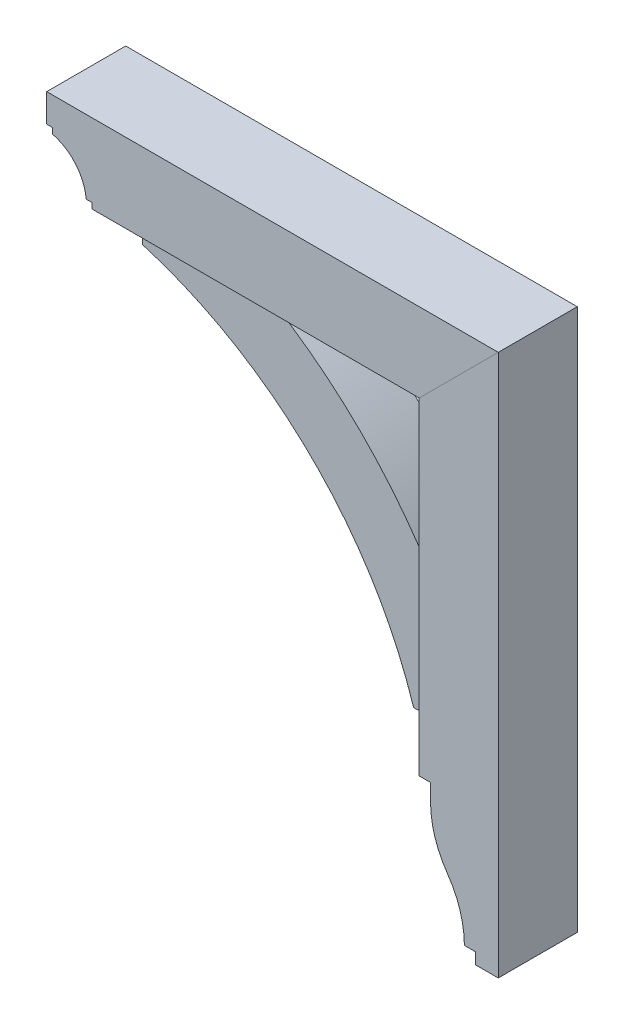
from build123d import *

# Parameters (mm, degrees)
BOSS_EXTRUDE1_DEPTH = 44.45
BOSS_EXTRUDE2_DEPTH = 31.75
BOSS_EXTRUDE3_DEPTH = 44.45


with BuildPart() as part:
    # Sketch1 → Boss-Extrude1 (new body, symmetric)
    with BuildSketch(Plane.XY):
        with BuildLine():
            Line((-178.568776984, 235.585), (-178.568776984, 241.935))
            Line((-178.568776984, 241.935), (-184.918776984, 241.935))
            Line((-184.918776984, 241.935), (-184.918776984, 273.685))
            Line((-184.918776984, 273.685), (323.081223016, 273.685))
            Line((323.081223016, 273.685), (234.181223016, 184.785))
            Line((234.181223016, 184.785), (-134.118776984, 184.785))
            Line((-134.118776984, 184.785), (-134.118776984, 191.135))
            Line((-134.118776984, 191.135), (-140.468776984, 191.135))
            ThreePointArc((-140.468776984, 191.135), (-152.460423906, 219.410016924), (-178.568776984, 235.585))
        make_face()
    extrude(amount=BOSS_EXTRUDE1_DEPTH, both=True)


with BuildPart() as body_2:
    # Sketch1_3 → Boss-Extrude2 (new body, symmetric)
    with BuildSketch(Plane.XY):
        with BuildLine():
            ThreePointArc((234.181223016, 6.985), (155.160715929, 106.653539725), (54.793723016, 184.785))
            Line((54.793723016, 184.785), (-89.668776984, 184.785))
            Line((-89.668776984, 184.785), (-89.668776984, 165.735))
            ThreePointArc((-89.668776984, 165.735), (99.67260633, 54.237370194), (215.131223016, -132.715))
            Line((215.131223016, -132.715), (234.181223016, -132.715))
            Line((234.181223016, -132.715), (234.181223016, 6.985))
        make_face()
    extrude(amount=BOSS_EXTRUDE2_DEPTH, both=True)


with BuildPart() as body_3:
    # Sketch1_4 → Boss-Extrude3 (new body, symmetric)
    with BuildSketch(Plane.XY):
        with BuildLine():
            Line((323.081223016, -335.915), (323.081223016, 273.685))
            Line((323.081223016, 273.685), (234.181223016, 184.785))
            Line((234.181223016, 184.785), (234.181223016, -183.515))
            Line((234.181223016, -183.515), (246.881223016, -183.515))
            Line((246.881223016, -183.515), (246.881223016, -202.565))
            ThreePointArc((246.881223016, -202.565), (251.744599276, -234.116039076), (265.883238129, -262.738047859))
            ThreePointArc((265.883238129, -262.738047859), (280.093284249, -291.504612242), (284.981223016, -323.215))
            Line((284.981223016, -323.215), (297.681223016, -323.215))
            Line((297.681223016, -323.215), (297.681223016, -335.915))
            Line((297.681223016, -335.915), (323.081223016, -335.915))
        make_face()
    extrude(amount=BOSS_EXTRUDE3_DEPTH, both=True)


solid = Compound([part.part, body_2.part, body_3.part])
